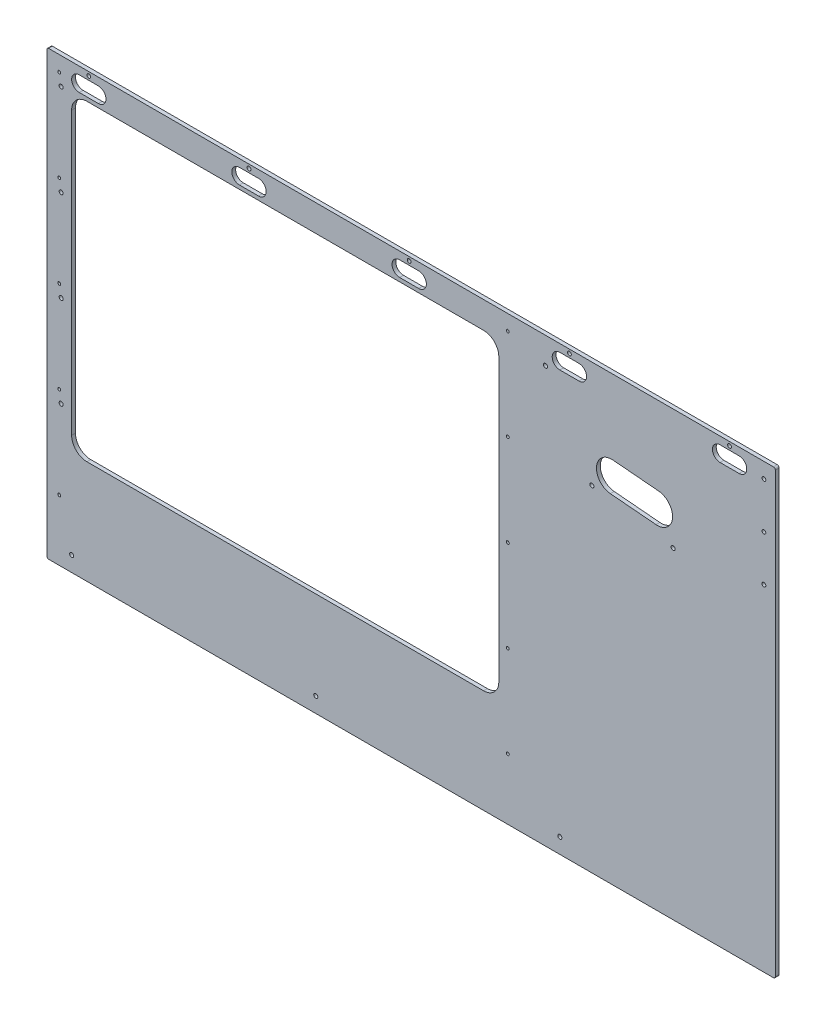
from build123d import *

# Parameters (mm, degrees)
SKETCH1_W                   = 1212.85
SKETCH1_H                   = 736.6
BOSS_EXTRUDE1_DEPTH         = 6.35
H_0_266_DIAMETER_HOLE1_D    = 6.7564
SKETCH2_R                   = 2.45745
SKETCH2_W                   = 711.2
SKETCH2_H                   = 519.684
CUT_EXTRUDE1_DEPTH          = 7.35
H_0_266_DIAMETER_HOLE2_D    = 6.7564
H_0_266_DIAMETER_HOLE3_D    = 6.7564
SKETCH12_R                  = 3.175
CUT_EXTRUDE4_DEPTH          = 7.35
LPATTERN1_COUNT             = 5
LPATTERN1_PITCH             = 266.7
FILLET1_R                   = 3.175
CUT_EXTRUDE5_DEPTH          = 7.35
F_1_4_0_25_DIAMETER_HOLE1_D = 6.35
FILLET2_R                   = 25.4


with BuildPart() as part:
    # Sketch1 → Boss-Extrude1 (new body)
    with BuildSketch(Plane.XY):
        Rectangle(SKETCH1_W, SKETCH1_H)
    extrude(amount=BOSS_EXTRUDE1_DEPTH)

    # H (0.266) Diameter Hole1 (through all)
    with Locations(Plane.XY.offset(6.35)):
        with Locations((-565.15, -342.9), (-158.75, -342.9), (247.65, -342.9)):
            Hole(H_0_266_DIAMETER_HOLE1_D / 2)

    # Sketch2 → Cut-Extrude1 (cut, through all)
    with BuildSketch(Plane.XY.offset(6.35)):
        with Locations((-585.7875, 342.9)):
            Circle(SKETCH2_R)
        with Locations((-585.7875, 190.5)):
            Circle(SKETCH2_R)
        with Locations((-585.7875, 38.1)):
            Circle(SKETCH2_R)
        with Locations((-585.7875, -114.3)):
            Circle(SKETCH2_R)
        with Locations((-585.7875, -266.7)):
            Circle(SKETCH2_R)
        with Locations((160.9725, -266.7)):
            Circle(SKETCH2_R)
        with Locations((160.9725, -114.3)):
            Circle(SKETCH2_R)
        with Locations((160.9725, 38.1)):
            Circle(SKETCH2_R)
        with Locations((160.9725, 190.5)):
            Circle(SKETCH2_R)
        with Locations((160.9725, 342.9)):
            Circle(SKETCH2_R)
        with Locations((-209.55, 64.008)):
            Rectangle(SKETCH2_W, SKETCH2_H)
    extrude(amount=-CUT_EXTRUDE1_DEPTH, mode=Mode.SUBTRACT)

    # H (0.266) Diameter Hole2 (through all)
    with Locations(Plane.XY.offset(6.35)):
        with Locations((-582.6125, 323.596), (-582.6125, 171.196), (-582.6125, 18.796), (-582.6125, -133.604)):
            Hole(H_0_266_DIAMETER_HOLE2_D / 2)

    # H (0.266) Diameter Hole3 (through all)
    with Locations(Plane.XY.offset(6.35)):
        with Locations((223.770763786, 324.305909426), (436.157707656, 167.711380391), (301.059784222, 190.437399182)):
            Hole(H_0_266_DIAMETER_HOLE3_D / 2)

    # Sketch12 → Cut-Extrude4 (cut, through all)
    with BuildSketch(Plane.XY.offset(6.35)):
        with Locations((-536.575, 361.95)):
            Circle(SKETCH12_R)
        with BuildLine():
            Line((-552.45, 355.6), (-520.7, 355.6))
            ThreePointArc((-520.7, 355.6), (-508, 342.9), (-520.7, 330.2))
            Line((-520.7, 330.2), (-552.45, 330.2))
            ThreePointArc((-552.45, 330.2), (-565.15, 342.9), (-552.45, 355.6))
        make_face()
    cut_extrude4 = extrude(amount=-CUT_EXTRUDE4_DEPTH, mode=Mode.SUBTRACT)

    # LPattern1: Cut-Extrude4 ×5
    with Locations(*[(i * LPATTERN1_PITCH, 0, 0) for i in range(1, LPATTERN1_COUNT)]):
        add(cut_extrude4, mode=Mode.SUBTRACT)

    # Fillet1
    fillet1_edges = [part.edges().sort_by_distance(p)[0] for p in [
        (606.425, -368.3, 3.175),
        (-606.425, -368.3, 3.175),
        (-606.425, 368.3, 3.175),
        (606.425, 368.3, 3.175),
    ]]
    fillet(fillet1_edges, radius=FILLET1_R)

    # Sketch14 → Cut-Extrude5 (cut, through all)
    with BuildSketch(Plane.XY.offset(6.35)):
        with BuildLine():
            Line((336.240912114, 244.52397913), (412.150948109, 237.882711533))
            ThreePointArc((412.150948109, 237.882711533), (435.240537575, 210.365610336), (407.723436378, 187.27602087))
            Line((407.723436378, 187.27602087), (331.813400383, 193.917288467))
            ThreePointArc((331.813400383, 193.917288467), (308.723810917, 221.434389664), (336.240912114, 244.52397913))
        make_face()
    extrude(amount=-CUT_EXTRUDE5_DEPTH, mode=Mode.SUBTRACT)

    # 1/4 (0.25) Diameter Hole1 (through all)
    with Locations(Plane.XY.offset(6.35)):
        with Locations((587.375, 342.9), (587.375, 266.7), (587.375, 190.5)):
            Hole(F_1_4_0_25_DIAMETER_HOLE1_D / 2)

    # Fillet2
    fillet2_edges = [part.edges().sort_by_distance(p)[0] for p in [
        (-565.15, -195.834, 3.175),
        (-565.15, 323.85, 3.175),
        (146.05, 323.85, 3.175),
        (146.05, -195.834, 3.175),
    ]]
    fillet(fillet2_edges, radius=FILLET2_R)


solid = part.part
